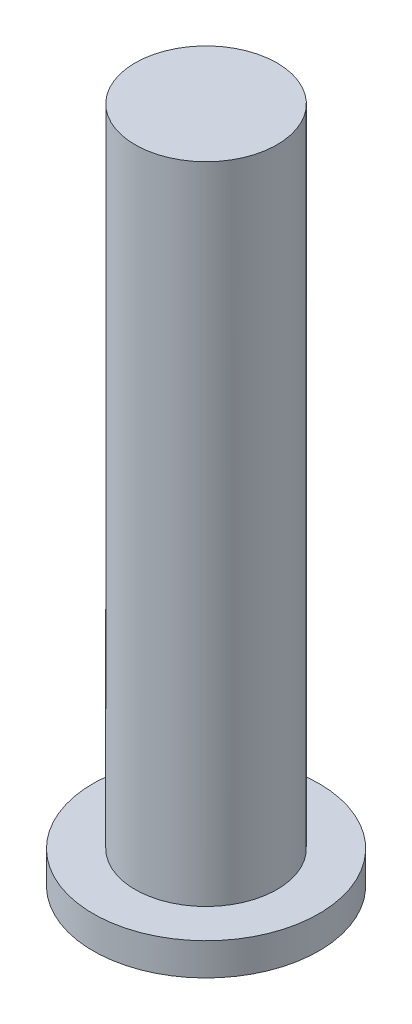
from build123d import *

# Parameters (mm, degrees)
SKETCH_2_R          = 3.5
SKETCH_2_R_2        = 1.65
EXTRUDE_1_DEPTH     = 1
SKETCH_3_R          = 2.2
EXTRUDE_2_DEPTH     = 20
SKETCH_6_R          = 1.65
CUT_EXTRUDE_1_DEPTH = 10


with BuildPart() as part:
    # 草图2 → 凸台-拉伸1 (new body)
    with BuildSketch(Plane.XZ):
        with Locations((96.952704723, -8.683144071)):
            Circle(SKETCH_2_R)
        with Locations((96.952704723, -8.683144071)):
            Circle(SKETCH_2_R_2, mode=Mode.SUBTRACT)
    extrude(amount=EXTRUDE_1_DEPTH)

    # 草图3 → 凸台-拉伸2 (add)
    with BuildSketch(Plane(origin=(0, 0, 0), x_dir=(1, 0, 0), z_dir=(0, 1, 0))):
        with Locations((96.952704723, 8.683144071)):
            Circle(SKETCH_3_R)
    extrude(amount=EXTRUDE_2_DEPTH)

    # 草图6 → 切除-拉伸1 (cut)
    with BuildSketch(Plane.XZ):
        with Locations((96.952704723, -8.683144071)):
            Circle(SKETCH_6_R)
    extrude(amount=-CUT_EXTRUDE_1_DEPTH, mode=Mode.SUBTRACT)


solid = part.part
